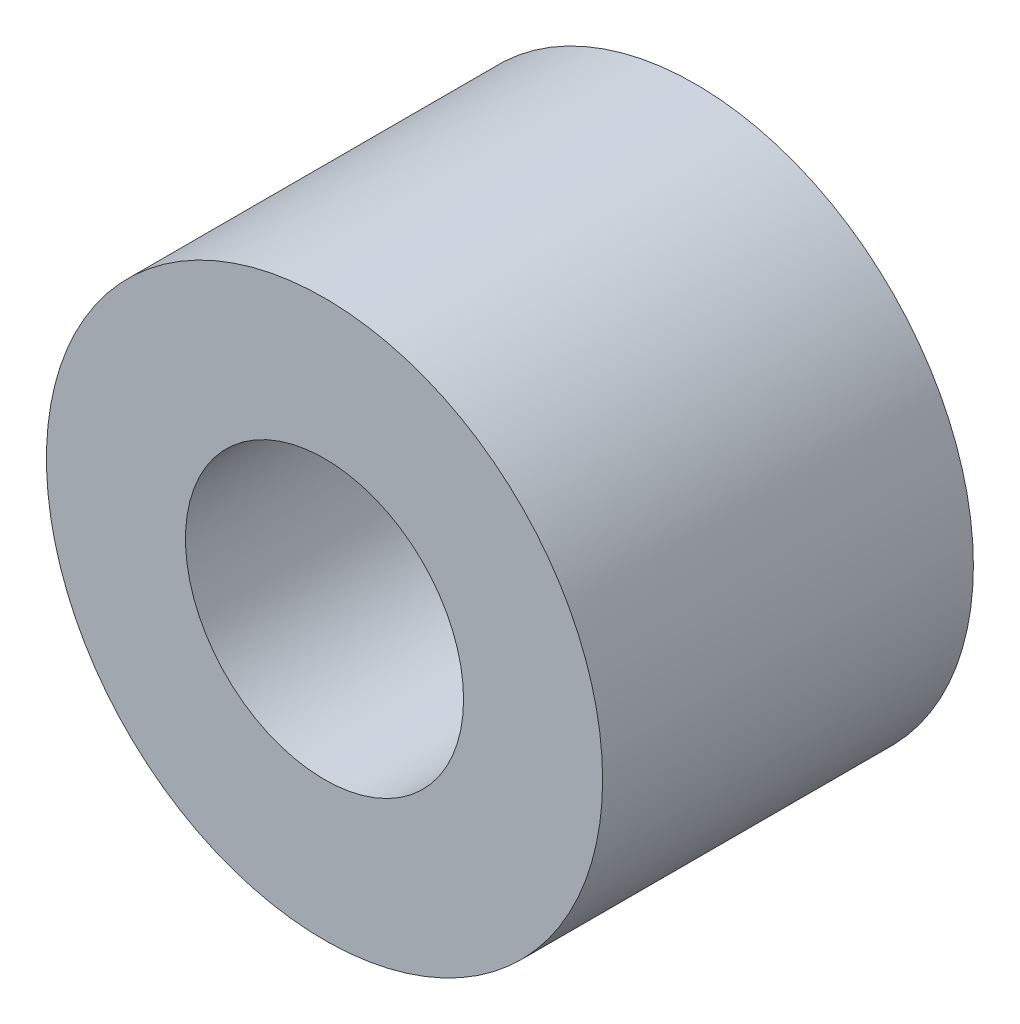
from build123d import *

# Parameters (mm, degrees)
SKETCH1_R      = 19.05
SKETCH1_R_2    = 9.525
EXTRUDE1_DEPTH = 12.7


with BuildPart() as part:
    # Sketch1 → Extrude1 (new body, symmetric)
    with BuildSketch(Plane.XY):
        Circle(SKETCH1_R)
        Circle(SKETCH1_R_2, mode=Mode.SUBTRACT)
    extrude(amount=EXTRUDE1_DEPTH, both=True)


solid = part.part
